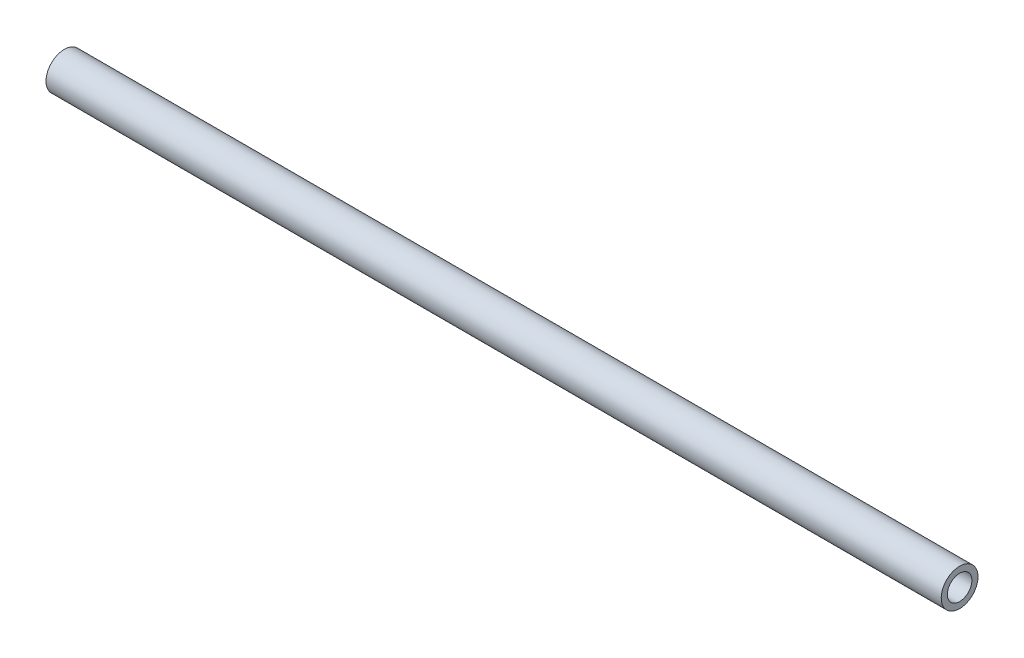
from build123d import *

# Parameters (mm, degrees)
SKETCH13_R                          = 9.525
SKETCH13_R_2                        = 6.35
ROUND_75IN_X_125IN_SIDEWALL_1_DEPTH = 463.55


with BuildPart() as part:
    # Sketch13 → Round .75IN X .125IN SIDEWALL(1) (new body)
    with BuildSketch(Plane(origin=(231.775, 0, 0), x_dir=(0, -1, 0), z_dir=(-1, 0, 0))):
        Circle(SKETCH13_R)
        Circle(SKETCH13_R_2, mode=Mode.SUBTRACT)
    extrude(amount=ROUND_75IN_X_125IN_SIDEWALL_1_DEPTH)


solid = part.part
